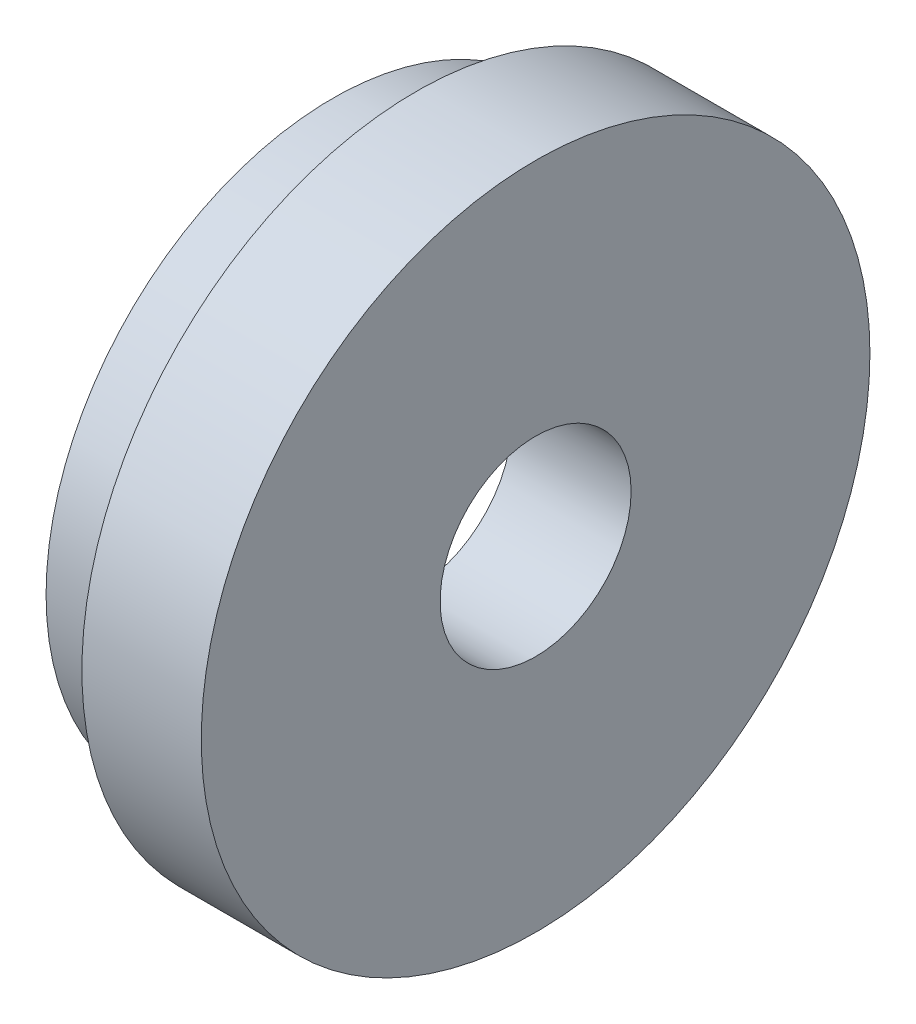
from build123d import *

# Parameters (mm, degrees)
CROQUIS1_R              = 14
CROQUIS1_R_2            = 4
SALIENTE_EXTRUIR1_DEPTH = 5
CROQUIS2_R              = 12
CROQUIS2_R_2            = 11
SALIENTE_EXTRUIR2_DEPTH = 3.5


with BuildPart() as part:
    # Croquis1 → Saliente-Extruir1 (new body)
    with BuildSketch(Plane(origin=(0, 0, 0), x_dir=(0, 0, -1), z_dir=(1, 0, 0))):
        Circle(CROQUIS1_R)
        Circle(CROQUIS1_R_2, mode=Mode.SUBTRACT)
    extrude(amount=SALIENTE_EXTRUIR1_DEPTH)

    # Croquis2 → Saliente-Extruir2 (add)
    with BuildSketch(Plane.ZY):
        Circle(CROQUIS2_R)
        Circle(CROQUIS2_R_2, mode=Mode.SUBTRACT)
    extrude(amount=SALIENTE_EXTRUIR2_DEPTH)


solid = part.part
